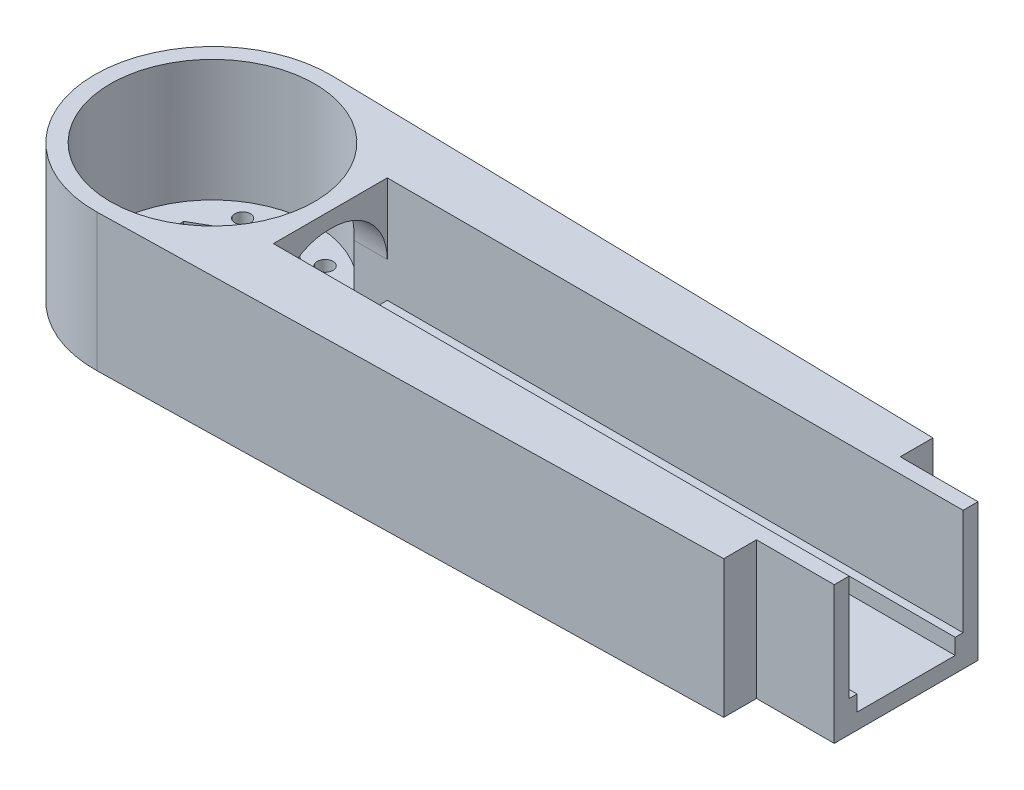
from build123d import *

# Parameters (mm, degrees)
BOSS_EXTRUDE1_DEPTH     = 17.5
SKETCH2_W               = 252
SKETCH2_H               = 14.5
CUT_EXTRUDE1_DEPTH      = 15.5
SKETCH3_R               = 13
CUT_EXTRUDE2_DEPTH      = 15.5
CUT_EXTRUDE3_REACH      = 264.265
CUT_EXTRUDE3_END_RADIUS = 13
SKETCH5_W               = 252
SKETCH5_H               = 1
BOSS_EXTRUDE2_DEPTH     = 2
SKETCH6_R               = 1
CUT_EXTRUDE4_DEPTH      = 2
CUT_EXTRUDE9_DEPTH      = 278.209870862


with BuildPart() as part:
    # Sketch1 → Boss-Extrude1 (new body)
    with BuildSketch(Plane(origin=(0, 0, 0), x_dir=(1, 0, 0), z_dir=(0, 1, 0))):
        with BuildLine():
            Line((0.323033708, 14.996521237), (267.19920412, 9.247854763))
            ThreePointArc((267.19920412, 9.247854763), (276.25, 0), (267.19920412, -9.247854763))
            Line((267.19920412, -9.247854763), (0.323033708, -14.996521237))
            ThreePointArc((0.323033708, -14.996521237), (-15, 0), (0.323033708, 14.996521237))
        make_face()
    extrude(amount=BOSS_EXTRUDE1_DEPTH)

    # Sketch2 → Cut-Extrude1 (cut)
    with BuildSketch(Plane(origin=(0, 17.5, 0), x_dir=(1, 0, 0), z_dir=(0, 1, 0))):
        with Locations((141, 0)):
            Rectangle(SKETCH2_W, SKETCH2_H)
    extrude(amount=-CUT_EXTRUDE1_DEPTH, mode=Mode.SUBTRACT)

    # Sketch3 → Cut-Extrude2 (cut)
    with BuildSketch(Plane(origin=(0, 17.5, 0), x_dir=(1, 0, 0), z_dir=(0, 1, 0))):
        with Locations(Location((0, 0, 0), (0, 0, 270))):
            Circle(SKETCH3_R)
    extrude(amount=-CUT_EXTRUDE2_DEPTH, mode=Mode.SUBTRACT)

    # Cut-Extrude3: up to this cylinder (the profile starts outside it)
    cut_extrude3_end = Plane(origin=(0, 8.125709, 0), z_dir=(0, 1, 0)) * Cylinder(CUT_EXTRUDE3_END_RADIUS, 555.53, mode=Mode.PRIVATE)
    # Sketch4 → Cut-Extrude3 (cut, up to the surface)
    with BuildSketch(Plane(origin=(15, 0, 0), x_dir=(0, 0, -1), z_dir=(1, 0, 0)), mode=Mode.PRIVATE) as cut_extrude3_sk1:
        with BuildLine():
            Line((-7.25, 2), (7.25, 2))
            Line((7.25, 2), (7.25, 8.5))
            ThreePointArc((7.25, 8.5), (5.199747468, 13.449747468), (0.25, 15.5))
            Line((0.25, 15.5), (-0.25, 15.5))
            ThreePointArc((-0.25, 15.5), (-5.199747468, 13.449747468), (-7.25, 8.5))
            Line((-7.25, 8.5), (-7.25, 2))
        make_face()
    cut_extrude3_tool1 = extrude(cut_extrude3_sk1.sketch, amount=-CUT_EXTRUDE3_REACH, mode=Mode.PRIVATE) - cut_extrude3_end
    add(cut_extrude3_tool1.solids().sort_by_distance((15, 8.125709, 0))[0], mode=Mode.SUBTRACT)

    # Sketch5 → Boss-Extrude2 (add)
    with BuildSketch(Plane(origin=(0, 2, 0), x_dir=(1, 0, 0), z_dir=(0, 1, 0))):
        with Locations((141, 6.75)):
            Rectangle(SKETCH5_W, SKETCH5_H)
        with Locations((141, -6.75)):
            Rectangle(SKETCH5_W, SKETCH5_H)
    extrude(amount=BOSS_EXTRUDE2_DEPTH)

    # Sketch6 → Cut-Extrude4 (cut)
    with BuildSketch(Plane(origin=(0, 2, 0), x_dir=(1, 0, 0), z_dir=(0, 1, 0))):
        with Locations(Location((-5.25, 9.09326674, 0), (0, 0, 270))):
            Circle(SKETCH6_R)
        with Locations(Location((-10.5, 0, 0), (0, 0, 270))):
            Circle(SKETCH6_R)
        with Locations(Location((5.25, 9.09326674, 0), (0, 0, 270))):
            Circle(SKETCH6_R)
        with Locations(Location((10.5, 0, 0), (0, 0, 270))):
            Circle(SKETCH6_R)
        with Locations(Location((5.25, -9.09326674, 0), (0, 0, 270))):
            Circle(SKETCH6_R)
        with Locations(Location((-5.25, -9.09326674, 0), (0, 0, 270))):
            Circle(SKETCH6_R)
        Polygon((0, -10), (8.660254038, -5), (8.660254038, 5), (0, 10), (-8.660254038, 5), (-8.660254038, -5), align=None)
    extrude(amount=-CUT_EXTRUDE4_DEPTH, mode=Mode.SUBTRACT)

    # Sketch14 → Cut-Extrude9 (cut, through all)
    with BuildSketch(Plane(origin=(0, 0, 0), x_dir=(1, 0, 0), z_dir=(0, 1, 0))):
        Polygon((88.5, 9.35), (78.6, 9.35), (78.6, 35), (78.4, 35), (78.4, 9.15), (88.3, 9.15), (88.3, -9.15), (78.4, -9.15), (78.4, -35), (78.6, -35), (78.6, -9.35), (88.5, -9.35), align=None)
        Polygon((172.7, 9.15), (182.6, 9.15), (182.6, 35), (182.4, 35), (182.4, 9.35), (172.5, 9.35), (172.5, 9.25), (172.5, -9.35), (182.4, -9.35), (182.4, -35), (182.6, -35), (182.6, -9.15), (172.7, -9.15), align=None)
    extrude(amount=CUT_EXTRUDE9_DEPTH, mode=Mode.SUBTRACT)


with BuildPart() as cut_extrude9_kept_piece:
    # of the separate pieces the step leaves, the one the design keeps (cut_extrude9_pieces_kept)
    add(part.part.solids().sort_by_distance((78.4, 0, 13.314698399))[0])


solid = cut_extrude9_kept_piece.part
